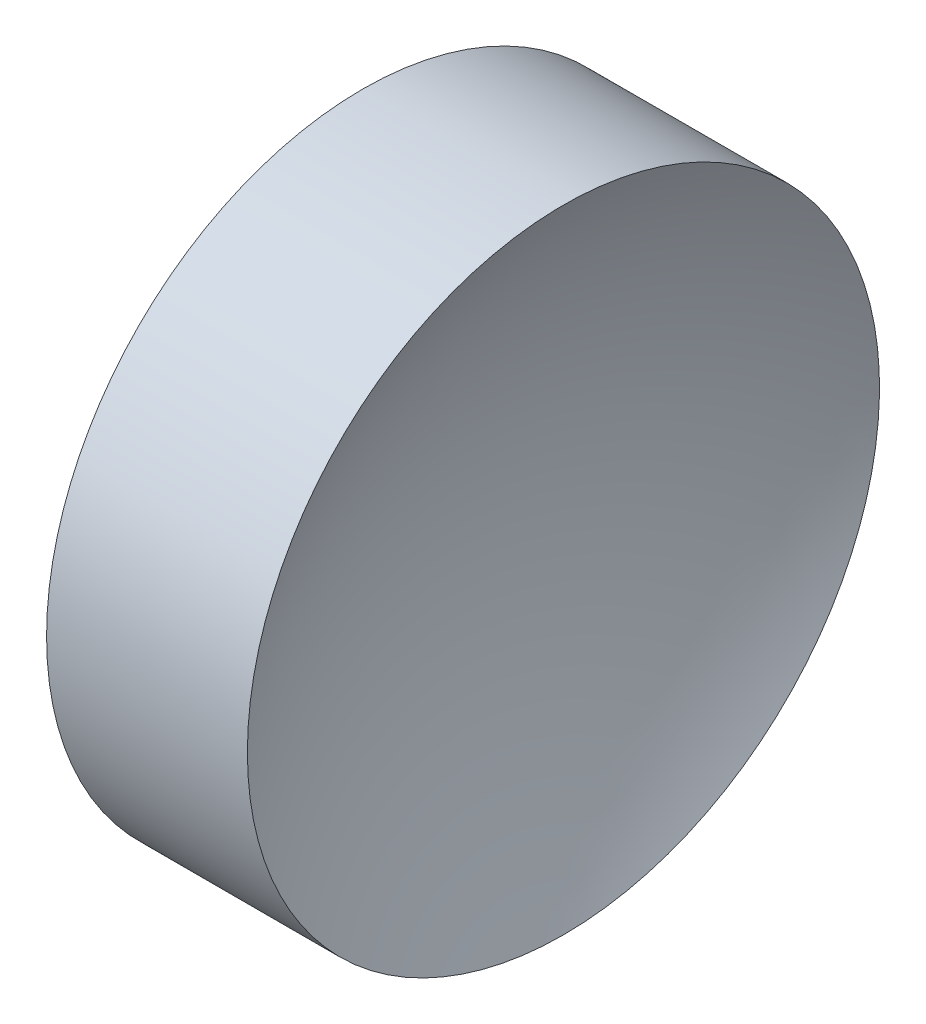
from build123d import *


with BuildPart() as part:
    # 草图1 → 旋转1 (revolve)
    with BuildSketch(Plane.XY, mode=Mode.PRIVATE) as revolve_1_sk:
        with BuildLine():
            Line((118.840931484, 65.222602873), (121.340931484, 65.222602873))
            ThreePointArc((121.340931484, 65.222602873), (122.636945784, 75.543049604), (126.444506986, 85.222602873))
            Line((126.444506986, 85.222602873), (120.090931484, 85.222602873))
            Line((120.090931484, 85.222602873), (113.737355982, 85.222602873))
            ThreePointArc((113.737355982, 85.222602873), (117.544917183, 75.543049604), (118.840931484, 65.222602873))
        make_face()
    revolve(revolve_1_sk.sketch.rotate(Axis((106.124652785, 65.222602873, 0), (1, 0, 0)), 90), axis=Axis((106.124652785, 65.222602873, 0), (1, 0, 0)))  # turned: the seam where the file's is


solid = part.part
